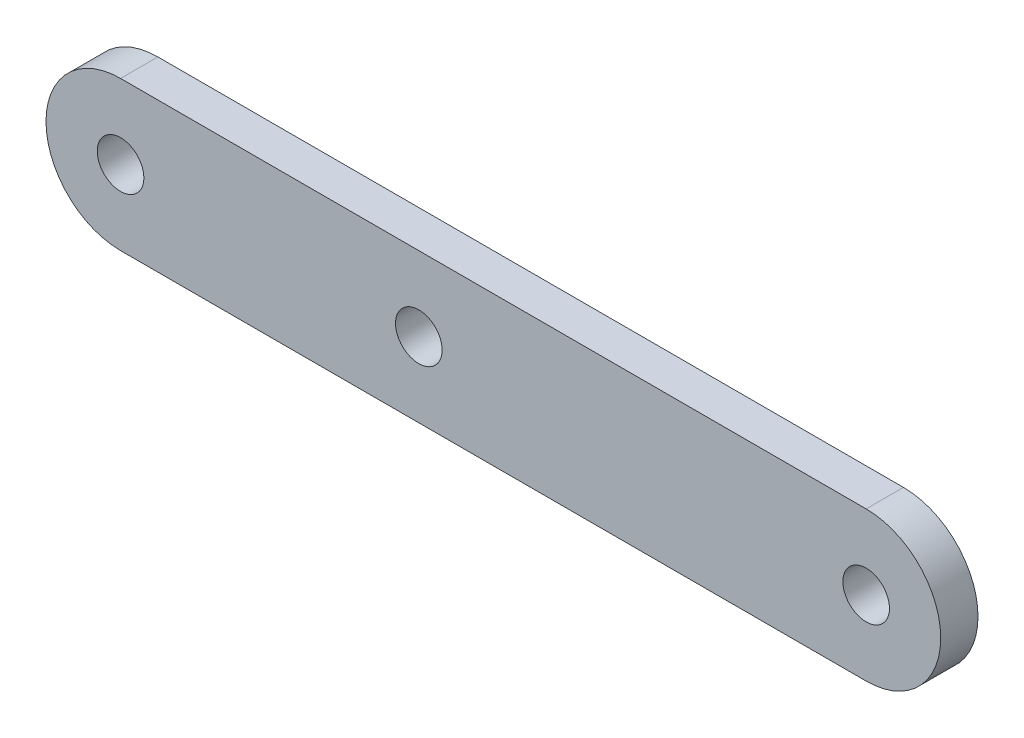
from build123d import *

# Parameters (mm, degrees)
SKETCH1_R      = 1.25
EXTRUDE1_DEPTH = 2


with BuildPart() as part:
    # Sketch1 → Extrude1 (new body)
    with BuildSketch(Plane.XY):
        with BuildLine():
            Line((20, -4), (-20, -4))
            ThreePointArc((-20, -4), (-24, 0), (-20, 4))
            Line((-20, 4), (20, 4))
            ThreePointArc((20, 4), (24, 0), (20, -4))
        make_face()
        with Locations((-20, 0)):
            Circle(SKETCH1_R, mode=Mode.SUBTRACT)
        with Locations((20, 0)):
            Circle(SKETCH1_R, mode=Mode.SUBTRACT)
        with Locations((-4, 0)):
            Circle(SKETCH1_R, mode=Mode.SUBTRACT)
    extrude(amount=EXTRUDE1_DEPTH)


solid = part.part
